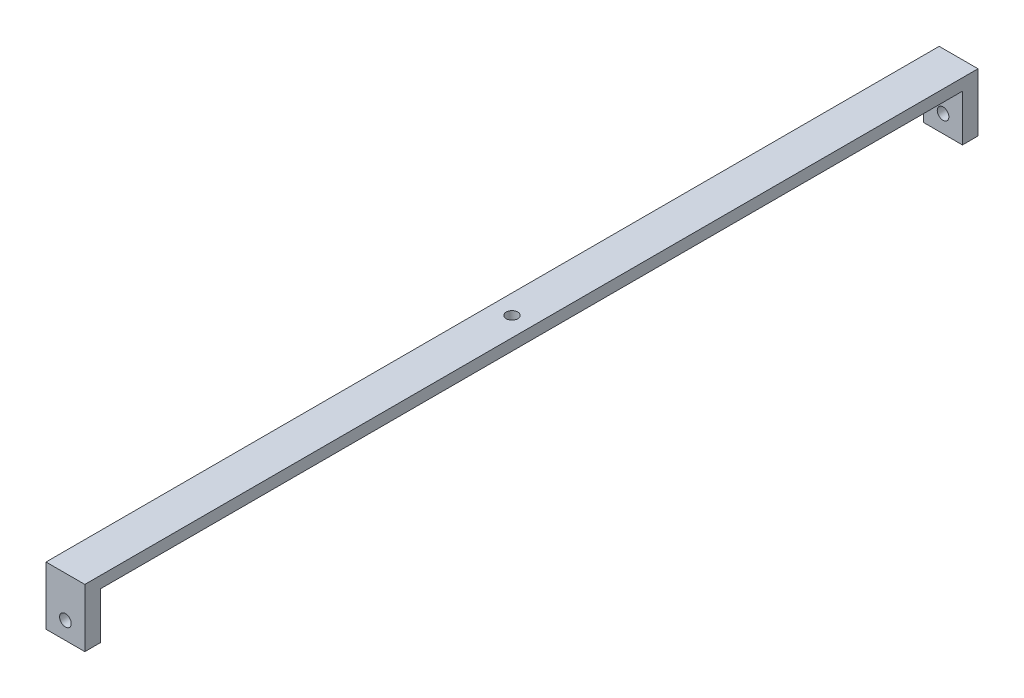
from build123d import *

# Parameters (mm, degrees)
CROQUIS1_W              = 10
CROQUIS1_H              = 15
CROQUIS1_R              = 1.5
SALIENTE_EXTRUIR1_DEPTH = 115
CROQUIS2_W              = 222
CROQUIS2_H              = 12
CORTAR_EXTRUIR1_DEPTH   = 11
CROQUIS3_R              = 1.5
CORTAR_EXTRUIR2_DEPTH   = 10


with BuildPart() as part:
    # Croquis1 → Saliente-Extruir1 (new body, symmetric)
    with BuildSketch(Plane.XY):
        Rectangle(CROQUIS1_W, CROQUIS1_H)
        with Locations((0, -3)):
            Circle(CROQUIS1_R, mode=Mode.SUBTRACT)
    extrude(amount=SALIENTE_EXTRUIR1_DEPTH, both=True)

    # Croquis2 → Cortar-Extruir1 (cut, through all)
    with BuildSketch(Plane.ZY.offset(5)):
        with Locations((0, -1.5)):
            Rectangle(CROQUIS2_W, CROQUIS2_H)
    extrude(amount=-CORTAR_EXTRUIR1_DEPTH, mode=Mode.SUBTRACT)

    # Croquis3 → Cortar-Extruir2 (cut)
    with BuildSketch(Plane(origin=(0, 7.5, 0), x_dir=(1, 0, 0), z_dir=(0, 1, 0))):
        Circle(CROQUIS3_R)
    extrude(amount=-CORTAR_EXTRUIR2_DEPTH, mode=Mode.SUBTRACT)


solid = part.part
